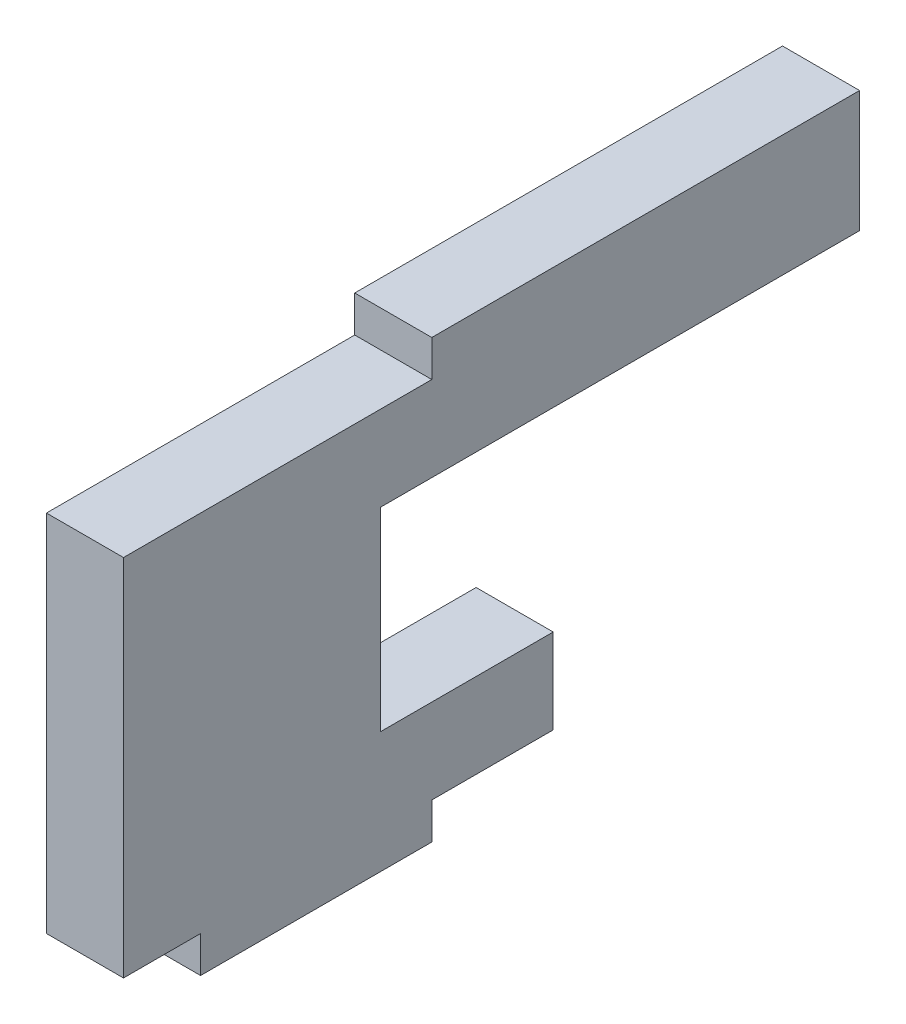
from build123d import *

# Parameters (mm, degrees)
SKETCH1_W           = 16.5
SKETCH1_H           = 43
BOSS_EXTRUDE1_DEPTH = 3.175
SKETCH2_W           = 9.525
SKETCH2_H           = 1.5
CUT_EXTRUDE1_DEPTH  = 10
SKETCH3_W           = 28.475
SKETCH3_H           = 11.5
CUT_EXTRUDE2_DEPTH  = 4.175
SKETCH5_W           = 3.175
SKETCH5_H           = 15
BOSS_EXTRUDE2_DEPTH = 3.175
SKETCH6_W           = 15.854218726
SKETCH6_H           = 5
SKETCH6_W_2         = 7.106349473
SKETCH6_H_2         = 8.006430413
CUT_EXTRUDE4_DEPTH  = 10
SKETCH7_W           = 9.525
SKETCH7_H           = 1.5
BOSS_EXTRUDE3_DEPTH = 3.175


with BuildPart() as part:
    # Sketch1 → Boss-Extrude1 (new body)
    with BuildSketch(Plane(origin=(0, 0, 0), x_dir=(0, -1, 0), z_dir=(1, 0, 0))):
        with Locations((8.25, 21.5)):
            Rectangle(SKETCH1_W, SKETCH1_H)
    extrude(amount=BOSS_EXTRUDE1_DEPTH)

    # Sketch2 → Cut-Extrude1 (cut)
    with BuildSketch(Plane(origin=(3.175, 0, 0), x_dir=(0, 0, -1), z_dir=(1, 0, 0))):
        with Locations((4.7625, -0.75)):
            Rectangle(SKETCH2_W, SKETCH2_H)
    extrude(amount=-CUT_EXTRUDE1_DEPTH, mode=Mode.SUBTRACT)

    # Sketch3 → Cut-Extrude2 (cut, through all)
    with BuildSketch(Plane(origin=(3.175, 0, 0), x_dir=(0, 0, -1), z_dir=(1, 0, 0))):
        with Locations((28.7625, -10.75)):
            Rectangle(SKETCH3_W, SKETCH3_H)
    extrude(amount=-CUT_EXTRUDE2_DEPTH, mode=Mode.SUBTRACT)

    # Sketch5 → Boss-Extrude2 (add)
    with BuildSketch(Plane(origin=(3.175, 0, 0), x_dir=(0, 0, -1), z_dir=(1, 0, 0))):
        with Locations((-1.5875, -9)):
            Rectangle(SKETCH5_W, SKETCH5_H)
    extrude(amount=-BOSS_EXTRUDE2_DEPTH)

    # Sketch6 → Cut-Extrude4 (cut)
    with BuildSketch(Plane(origin=(3.175, 0, 0), x_dir=(0, 0, -1), z_dir=(1, 0, 0))):
        with Locations((35.072890637, -2.5)):
            Rectangle(SKETCH6_W, SKETCH6_H)
        with Locations((10.971825264, -9.003215207)):
            Rectangle(SKETCH6_W_2, SKETCH6_H_2)
    extrude(amount=-CUT_EXTRUDE4_DEPTH, mode=Mode.SUBTRACT)

    # Sketch7 → Boss-Extrude3 (add)
    with BuildSketch(Plane(origin=(3.175, 0, 0), x_dir=(0, 0, -1), z_dir=(1, 0, 0))):
        with Locations((4.7625, -17.25)):
            Rectangle(SKETCH7_W, SKETCH7_H)
    extrude(amount=-BOSS_EXTRUDE3_DEPTH)


solid = part.part
